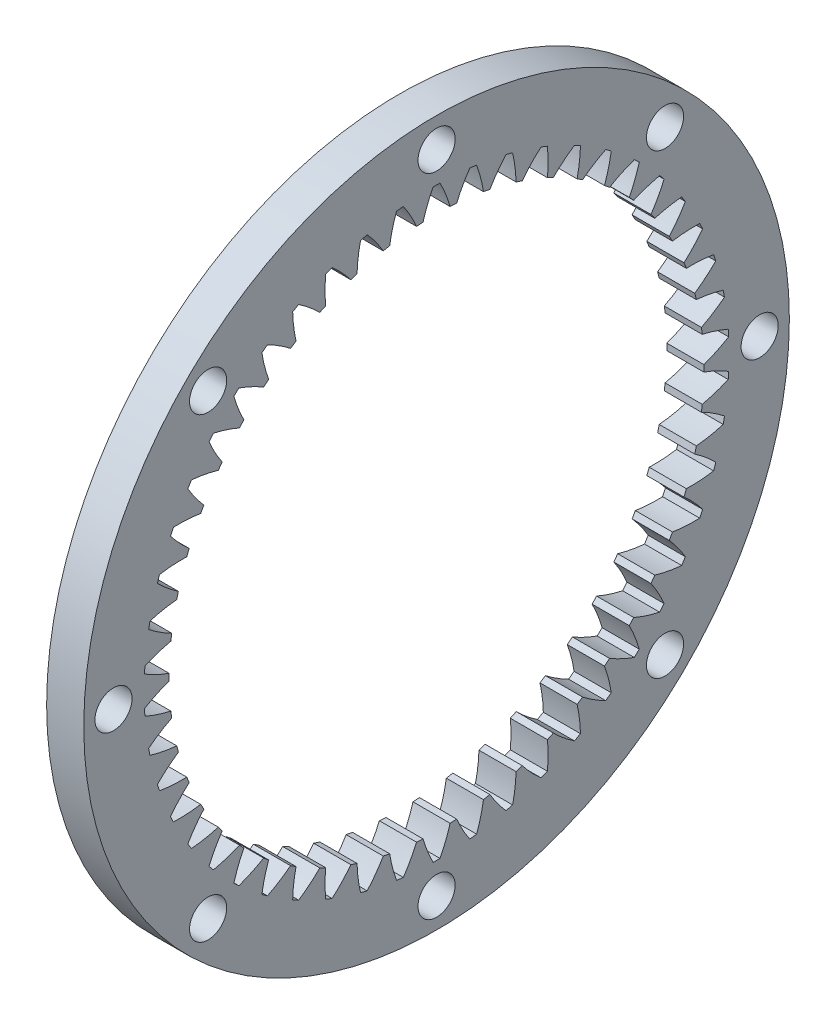
from build123d import *

# Parameters (mm, degrees)
BASPROSKE_W             = 20
BASPROSKE_H             = 23
TOOTHCUT_DEPTH          = 136.830777072
TEETHCUTS_COUNT         = 50
SKETCH1_R               = 1.75
CUT_EXTRUDE1_DEPTH      = 136.830777072
SKETCH2_R               = 5
CUT_EXTRUDE2_DEPTH      = 7.5
CIRPATTERN1_COUNT       = 8
SKETCH3_W               = 10
SKETCH3_H               = 190.204406322
CUT_EXTRUDE3_DEPTH      = 136.830777072
CUT_EXTRUDE3_DEPTH_BACK = 136.830777072


with BuildPart() as part:
    # BasProSke → Base-Revolve (revolve)
    with BuildSketch(Plane(origin=(0, 0, 0), x_dir=(1, 0, 0), z_dir=(0, 1, 0)), mode=Mode.PRIVATE) as base_revolve_sk:
        with Locations((10, 83.5)):
            Rectangle(BASPROSKE_W, BASPROSKE_H)
    revolve(base_revolve_sk.sketch.rotate(Axis((-10, 0, 0), (1, 0, 0)), 180), axis=Axis((-10, 0, 0), (1, 0, 0)))

    # TooCutSke → ToothCut (cut, through all)
    with BuildSketch(Plane(origin=(0, 0, 0), x_dir=(0, 0, -1), z_dir=(1, 0, 0))):
        with BuildLine():
            ThreePointArc((3.65252583, 71.881862109), (2.456403267, 75.381149429), (0.92143366, 78.745609154))
            ThreePointArc((0.92143366, 78.745609154), (0, 78.751), (-0.92143366, 78.745609154))
            ThreePointArc((-0.92143366, 78.745609154), (-2.456403267, 75.381149429), (-3.65252583, 71.881862109))
            ThreePointArc((-3.65252583, 71.881862109), (0, 71.9746), (3.65252583, 71.881862109))
        make_face()
    toothcut = extrude(amount=TOOTHCUT_DEPTH, mode=Mode.SUBTRACT)

    # TeethCuts: ToothCut ×50 about axis
    teethcuts_axis = Axis((0, 0, 0), (1, 0, 0))
    for i in range(1, TEETHCUTS_COUNT):
        add(toothcut.rotate(teethcuts_axis, i * 360 / TEETHCUTS_COUNT), mode=Mode.SUBTRACT)

    # Sketch1 → Cut-Extrude1 (cut, through all)
    with BuildSketch(Plane(origin=(20, 0, 0), x_dir=(0, 0, -1), z_dir=(1, 0, 0))):
        with Locations((0, 87)):
            Circle(SKETCH1_R)
    cut_extrude1 = extrude(amount=-CUT_EXTRUDE1_DEPTH, mode=Mode.SUBTRACT)

    # Sketch2 → Cut-Extrude2 (cut)
    with BuildSketch(Plane(origin=(20, 0, 0), x_dir=(0, 0, -1), z_dir=(1, 0, 0))):
        with Locations((0, 87)):
            Circle(SKETCH2_R)
    cut_extrude2 = extrude(amount=-CUT_EXTRUDE2_DEPTH, mode=Mode.SUBTRACT)

    # CirPattern1: Cut-Extrude1, Cut-Extrude2 ×8 about axis
    cirpattern1_axis = Axis((0, 0, 0), (1, 0, 0))
    add([cut_extrude1.rotate(cirpattern1_axis, i * 360 / CIRPATTERN1_COUNT) for i in range(1, CIRPATTERN1_COUNT)], mode=Mode.SUBTRACT)
    add([cut_extrude2.rotate(cirpattern1_axis, i * 360 / CIRPATTERN1_COUNT) for i in range(1, CIRPATTERN1_COUNT)], mode=Mode.SUBTRACT)

    # Sketch3 → Cut-Extrude3 (cut, two sides)
    with BuildSketch(Plane.XY) as cut_extrude3_sk:
        with Locations((5, -0.102203161)):
            Rectangle(SKETCH3_W, SKETCH3_H)
    extrude(amount=CUT_EXTRUDE3_DEPTH, mode=Mode.SUBTRACT)
    extrude(cut_extrude3_sk.sketch, amount=-CUT_EXTRUDE3_DEPTH_BACK, mode=Mode.SUBTRACT)


solid = part.part
